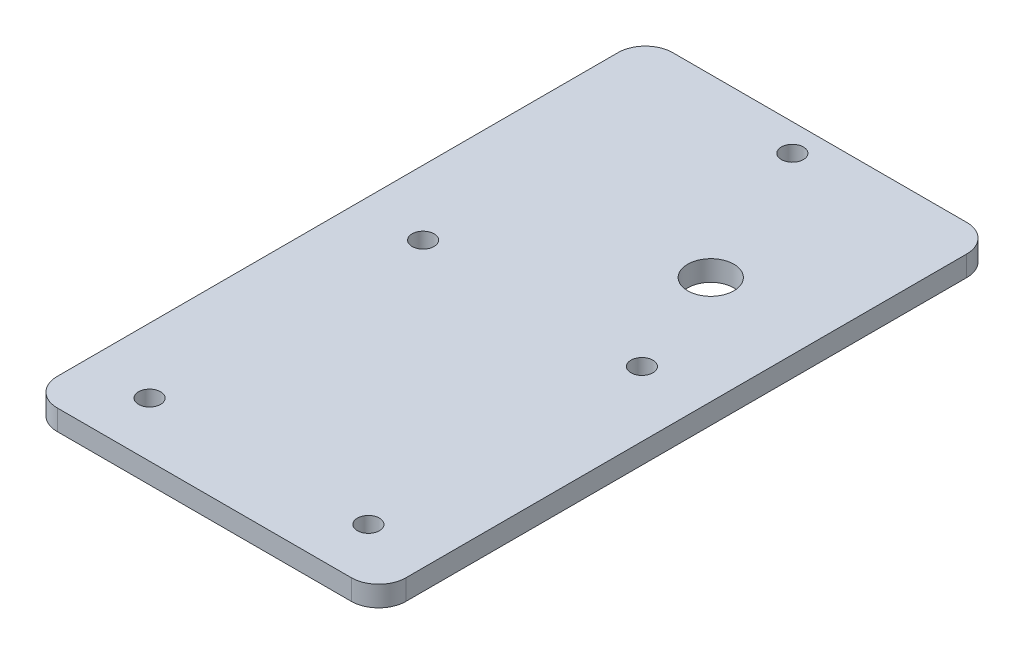
from build123d import *

# Parameters (mm, degrees)
SKETCH2_R                   = 2.5527
BOSS_EXTRUDE1_DEPTH         = 4.7625
F_1_2_13_TAPPED_HOLE1_D     = 10.71626
F_1_2_13_TAPPED_HOLE1_DEPTH = 4.7625
SKETCH5_R                   = 0.79375
CUT_EXTRUDE1_DEPTH          = 0.762
SKETCH6_W                   = 1.221153846
SKETCH6_H                   = 0.325641026
SKETCH6_W_2                 = 0.284935898
SKETCH6_H_2                 = 3.175
SKETCH6_H_3                 = 0.325641025
CUT_EXTRUDE2_DEPTH          = 0.7874


with BuildPart() as part:
    # Sketch2 → Boss-Extrude1 (new body)
    with BuildSketch(Plane(origin=(0, 0, 0), x_dir=(1, 0, 0), z_dir=(0, 1, 0))):
        with BuildLine():
            Line((-40.48125, 114.236868064), (-40.48125, -15.938131936))
            ThreePointArc((-40.48125, -15.938131936), (-38.621378061, -20.428259996), (-34.13125, -22.288131936))
            Line((-34.13125, -22.288131936), (34.13125, -22.288131936))
            ThreePointArc((34.13125, -22.288131936), (38.621378061, -20.428259996), (40.48125, -15.938131936))
            Line((40.48125, -15.938131936), (40.48125, 114.236868064))
            ThreePointArc((40.48125, 114.236868064), (38.621378061, 118.726996125), (34.13125, 120.586868064))
            Line((34.13125, 120.586868064), (-34.13125, 120.586868064))
            ThreePointArc((-34.13125, 120.586868064), (-38.621378061, 118.726996125), (-40.48125, 114.236868064))
        make_face()
        with Locations((-25.4, -9.588131936)):
            Circle(SKETCH2_R, mode=Mode.SUBTRACT)
        with Locations((25.4, -9.588131936)):
            Circle(SKETCH2_R, mode=Mode.SUBTRACT)
        with Locations((25.4, 53.911868064)):
            Circle(SKETCH2_R, mode=Mode.SUBTRACT)
        with Locations((-25.4, 53.911868064)):
            Circle(SKETCH2_R, mode=Mode.SUBTRACT)
        with Locations((0, 114.236868064)):
            Circle(SKETCH2_R, mode=Mode.SUBTRACT)
    extrude(amount=-BOSS_EXTRUDE1_DEPTH)

    # 1/2-13 Tapped Hole1
    with Locations(Plane(origin=(0, -4.7625, 0), x_dir=(-1, 0, 0), z_dir=(0, -1, 0))):
        with Locations((-15.49976282, 79.795252419)):
            Hole(F_1_2_13_TAPPED_HOLE1_D / 2, depth=F_1_2_13_TAPPED_HOLE1_DEPTH)

    # Sketch5 → Cut-Extrude1 (cut)
    with BuildSketch(Plane(origin=(0, -4.7625, 0), x_dir=(-1, 0, 0), z_dir=(0, -1, 0))):
        with Locations((0, -3.066681936)):
            Circle(SKETCH5_R)
        with Locations((-26.19375, 102.728581934)):
            Circle(SKETCH5_R)
        with Locations((26.19375, 102.728581934)):
            Circle(SKETCH5_R)
    extrude(amount=-CUT_EXTRUDE1_DEPTH, mode=Mode.SUBTRACT)

    # Sketch6 → Cut-Extrude2 (cut)
    with BuildSketch(Plane.XZ.offset(4.7625)):
        Polygon((10.463942238, -11.27657071), (10.406064634, -11.27657071), (10.406064634, -9.078493787), (10.03971848, -9.078493787), (10.03971848, -8.752852761), (10.406064634, -8.752852761), (10.406064634, -8.020160454), (10.691000531, -8.020160454), (10.691000531, -8.752852761), (12.197090275, -8.752852761), align=None)
        Polygon((10.691000531, -9.078493787), (10.691000531, -10.457380005), (11.637394762, -9.078493787), align=None, mode=Mode.SUBTRACT)
        with Locations((7.923051813, -9.2413143)):
            Rectangle(SKETCH6_W, SKETCH6_H)
        Polygon((5.806385147, -11.195160454), (5.501096685, -11.195160454), (4.442763352, -8.693067104), (3.384430018, -11.195160454), (3.079141557, -11.195160454), (4.422410788, -8.020160454), (4.463115916, -8.020160454), align=None)
        Polygon((2.468564634, -11.195160454), (0.677538993, -11.195160454), (0.677538993, -10.869519428), (2.183628736, -10.869519428), (2.183628736, -9.892596351), (0.677538993, -9.892596351), (0.677538993, -9.566955325), (2.183628736, -9.566955325), (2.183628736, -8.345801479), (0.677538993, -8.345801479), (0.677538993, -8.020160454), (2.468564634, -8.020160454), align=None)
        Polygon((0.107667198, -8.020160454), (0.107667198, -11.195160454), (0.047881541, -11.195160454), (-2.049704597, -8.696247192), (-2.049704597, -11.195160454), (-2.334640494, -11.195160454), (-2.334640494, -8.020160454), (-2.269766696, -8.020160454), (-0.1772687, -10.513349556), (-0.1772687, -8.020160454), align=None)
        Polygon((-2.782396905, -10.869519428), (-2.782396905, -11.195160454), (-4.451307161, -11.195160454), (-4.451307161, -10.869519428), (-3.759319982, -10.869519428), (-3.759319982, -8.020160454), (-3.474384084, -8.020160454), (-3.474384084, -10.869519428), align=None)
        with Locations((-6.384800751, -9.607660454)):
            Rectangle(SKETCH6_W_2, SKETCH6_H_2)
        Polygon((-7.219255879, -8.020160454), (-7.219255879, -11.195160454), (-7.279041536, -11.195160454), (-9.376627674, -8.696247192), (-9.376627674, -11.195160454), (-9.661563571, -11.195160454), (-9.661563571, -8.020160454), (-9.596689773, -8.020160454), (-7.504191776, -10.513349556), (-7.504191776, -8.020160454), align=None)
        with BuildLine():
            Line((-10.475666135, -11.195160454), (-11.098327393, -11.195160454))
            add(Edge.make_bspline(
                [(-11.098327393, -11.195160454), (-11.14115443, -11.195113376), (-11.223212933, -11.195023174), (-11.340883019, -11.192288369), (-11.447753276, -11.188635584), (-11.543593264, -11.183572009), (-11.628697868, -11.17758796), (-11.702681989, -11.169195038), (-11.766127158, -11.16043177), (-11.804142295, -11.151522351), (-11.821479437, -11.147459131)],
                knots=[0, 0, 0, 0, 0.000128477, 0.000246168, 0.000353087, 0.00044926, 0.000534089, 0.000608961, 0.000672646, 0.000726041, 0.000726041, 0.000726041, 0.000726041], degree=3))
            add(Edge.make_bspline(
                [(-11.821479437, -11.147459131), (-11.843426289, -11.141451896), (-11.886802842, -11.129578977), (-11.949307949, -11.105802008), (-12.008767162, -11.077596308), (-12.065429194, -11.045497724), (-12.11832336, -11.00799041), (-12.169101118, -10.967239159), (-12.216697585, -10.921595895), (-12.260394069, -10.87112071), (-12.300880749, -10.817467154), (-12.334771001, -10.759267087), (-12.364697428, -10.698539495), (-12.388019365, -10.633801694), (-12.406351303, -10.565908215), (-12.419702474, -10.494682353), (-12.428283556, -10.420277758), (-12.429097793, -10.369421701), (-12.429512289, -10.343532849)],
                knots=[0, 0, 0, 0, 6.8232e-05, 0.000134856, 0.000200292, 0.000265532, 0.000329934, 0.000394598, 0.000460723, 0.000527435, 0.000594727, 0.000662027, 0.00072916, 0.000797572, 0.000868081, 0.000939932, 0.001014804, 0.001092439, 0.001092439, 0.001092439, 0.001092439], degree=3))
            add(Edge.make_bspline(
                [(-12.429512289, -10.343532849), (-12.429129997, -10.317427295), (-12.428382016, -10.266350014), (-12.419404671, -10.191626127), (-12.407312283, -10.120217302), (-12.388718529, -10.052281872), (-12.364365668, -9.98822328), (-12.335797877, -9.927062591), (-12.301341389, -9.869840317), (-12.261749293, -9.816348718), (-12.217706061, -9.766537583), (-12.169398039, -9.720767877), (-12.117020252, -9.679307513), (-12.060739161, -9.642063544), (-12.000006084, -9.609899633), (-11.93574213, -9.581091221), (-11.867388719, -9.556896759), (-11.82008801, -9.544169489), (-11.796038732, -9.537698515)],
                knots=[0, 0, 0, 0, 7.8272e-05, 0.000153144, 0.000225504, 0.0002954, 0.000364034, 0.000430891, 0.000497646, 0.000564048, 0.000630282, 0.000696867, 0.000763418, 0.000830451, 0.000899029, 0.000969354, 0.001041572, 0.001116269, 0.001116269, 0.001116269, 0.001116269], degree=3))
            add(Edge.make_bspline(
                [(-11.796038732, -9.537698515), (-11.776147281, -9.533471677), (-11.73255401, -9.524208317), (-11.660764756, -9.513796559), (-11.57713832, -9.505257781), (-11.481959236, -9.497289324), (-11.375005548, -9.493067038), (-11.256522557, -9.488109386), (-11.126109277, -9.485770141), (-11.035150079, -9.485622272), (-10.987660326, -9.485545069)],
                knots=[0, 0, 0, 0, 6.0995e-05, 0.000133673, 0.000217466, 0.000313174, 0.000420146, 0.000538529, 0.000668937, 0.000811407, 0.000811407, 0.000811407, 0.000811407], degree=3))
            Line((-10.987660326, -9.485545069), (-10.760602033, -9.485545069))
            Line((-10.760602033, -9.485545069), (-10.760602033, -8.020160454))
            Line((-10.760602033, -8.020160454), (-10.475666135, -8.020160454))
            Line((-10.475666135, -8.020160454), (-10.475666135, -11.195160454))
        make_face()
        with BuildLine():
            Line((-10.760602033, -10.869519428), (-10.760602033, -9.811186095))
            Line((-10.760602033, -9.811186095), (-11.31648144, -9.804189901))
            add(Edge.make_bspline(
                [(-11.31648144, -9.804189901), (-11.343623544, -9.804172004), (-11.396020816, -9.804137455), (-11.471914654, -9.807814614), (-11.542157112, -9.811814948), (-11.6068519, -9.818284437), (-11.665703733, -9.826175199), (-11.718855099, -9.836725186), (-11.766730172, -9.847485491), (-11.821876954, -9.866156531), (-11.883647133, -9.894324164), (-11.950689653, -9.936396036), (-12.007971989, -9.989396015), (-12.057122984, -10.049631041), (-12.095973489, -10.116710556), (-12.124130134, -10.188282461), (-12.141316365, -10.264074986), (-12.143476529, -10.31588259), (-12.144576392, -10.342260814)],
                knots=[0, 0, 0, 0, 8.1413e-05, 0.000157166, 0.000227904, 0.000292456, 0.00035218, 0.000405942, 0.000454998, 0.000499245, 0.00058036, 0.000658165, 0.000735602, 0.000813379, 0.000890612, 0.000967146, 0.001043375, 0.001122449, 0.001122449, 0.001122449, 0.001122449], degree=3))
            add(Edge.make_bspline(
                [(-12.144576392, -10.342260814), (-12.143427459, -10.367784457), (-12.141143524, -10.4185223), (-12.124272098, -10.492918381), (-12.095675301, -10.563676625), (-12.057091311, -10.630224472), (-12.009118146, -10.690299403), (-11.952975038, -10.742118206), (-11.889535486, -10.784059461), (-11.830983415, -10.811979354), (-11.778583924, -10.828352201), (-11.733289329, -10.840172568), (-11.681886893, -10.848324823), (-11.624863074, -10.856124998), (-11.562290882, -10.862421437), (-11.493772435, -10.866793885), (-11.419535964, -10.869326008), (-11.368000902, -10.869453394), (-11.341286127, -10.869519428)],
                knots=[0, 0, 0, 0, 7.6536e-05, 0.000152145, 0.000227496, 0.00030473, 0.000382107, 0.000457279, 0.000532954, 0.000609493, 0.000650927, 0.000697513, 0.000749794, 0.000806912, 0.000870198, 0.000938398, 0.001012855, 0.001092996, 0.001092996, 0.001092996, 0.001092996], degree=3))
            Line((-11.341286127, -10.869519428), (-10.760602033, -10.869519428))
        make_face(mode=Mode.SUBTRACT)
        with BuildLine():
            Line((-13.080794341, -11.195160454), (-13.365730238, -11.195160454))
            Line((-13.365730238, -11.195160454), (-13.365730238, -9.292831728))
            add(Edge.make_bspline(
                [(-13.365730238, -9.292831728), (-13.365687835, -9.26590706), (-13.365607367, -9.214812864), (-13.366144861, -9.142088763), (-13.367650146, -9.077434461), (-13.368599162, -9.020600738), (-13.370710386, -8.971848389), (-13.372432185, -8.930913285), (-13.374646119, -8.897989259), (-13.377306876, -8.878775133), (-13.378450591, -8.870516023)],
                knots=[0, 0, 0, 0, 8.0774e-05, 0.000153283, 0.000218169, 0.000274789, 0.0003238, 0.00036455, 0.00039772, 0.000422728, 0.000422728, 0.000422728, 0.000422728], degree=3))
            add(Edge.make_bspline(
                [(-13.378450591, -8.870516023), (-13.383089171, -8.840488218), (-13.392043743, -8.782520892), (-13.415920368, -8.700076695), (-13.447491551, -8.625379836), (-13.487726264, -8.55759573), (-13.53735061, -8.496247781), (-13.598577204, -8.440746172), (-13.671279677, -8.390931006), (-13.75380491, -8.347234252), (-13.841789998, -8.310993067), (-13.932015226, -8.283862018), (-14.022757057, -8.267260812), (-14.083515506, -8.265343381), (-14.113686969, -8.264391223)],
                knots=[0, 0, 0, 0, 9.1077e-05, 0.00017582, 0.000256745, 0.000333753, 0.000411529, 0.000492561, 0.000580775, 0.000675242, 0.000772212, 0.000865784, 0.000957488, 0.001047945, 0.001047945, 0.001047945, 0.001047945], degree=3))
            add(Edge.make_bspline(
                [(-14.113686969, -8.264391223), (-14.139591615, -8.265359905), (-14.191251288, -8.267291674), (-14.267966792, -8.27940291), (-14.342922766, -8.300795507), (-14.415514195, -8.329951917), (-14.484621558, -8.365749352), (-14.54838686, -8.40893079), (-14.606138591, -8.458496536), (-14.658219839, -8.514214383), (-14.703551796, -8.576425768), (-14.742575743, -8.644806567), (-14.774460374, -8.719902176), (-14.790478073, -8.772825319), (-14.798677954, -8.799918066)],
                knots=[0, 0, 0, 0, 7.7722e-05, 0.000154995, 0.000232312, 0.000311088, 0.000389321, 0.000465351, 0.00054158, 0.000617184, 0.000693638, 0.000771974, 0.000852899, 0.000937778, 0.000937778, 0.000937778, 0.000937778], degree=3))
            add(Edge.make_bspline(
                [(-14.798677954, -8.799918066), (-14.801399497, -8.811119987), (-14.807464189, -8.836082381), (-14.813131152, -8.878283838), (-14.8190335, -8.928076332), (-14.82312886, -8.985817619), (-14.827121395, -9.051314216), (-14.829509969, -9.124907321), (-14.830613991, -9.206329707), (-14.830942994, -9.263150561), (-14.831114853, -9.292831728)],
                knots=[0, 0, 0, 0, 3.4562e-05, 7.7018e-05, 0.000127589, 0.000185003, 0.000250624, 0.000324446, 0.000405866, 0.000494911, 0.000494911, 0.000494911, 0.000494911], degree=3))
            Line((-14.831114853, -9.292831728), (-14.831114853, -11.195160454))
            Line((-14.831114853, -11.195160454), (-15.116050751, -11.195160454))
            Line((-15.116050751, -11.195160454), (-15.116050751, -9.277567305))
            add(Edge.make_bspline(
                [(-15.116050751, -9.277567305), (-15.115822744, -9.243006266), (-15.115377774, -9.175558299), (-15.111441581, -9.076728934), (-15.105344791, -8.982955061), (-15.096135163, -8.894354644), (-15.085944786, -8.810827971), (-15.071487885, -8.732680977), (-15.056113374, -8.659250702), (-15.036818573, -8.590401703), (-15.013866331, -8.525095139), (-14.986533502, -8.462097498), (-14.953243671, -8.401975585), (-14.915561716, -8.343627255), (-14.872716131, -8.287590229), (-14.825072252, -8.233429669), (-14.771867518, -8.181857589), (-14.714442844, -8.132627433), (-14.653264457, -8.086519375), (-14.587645992, -8.047262144), (-14.518762035, -8.014038155), (-14.447343141, -7.985740439), (-14.372182226, -7.965047675), (-14.294215494, -7.949511879), (-14.212894994, -7.940723242), (-14.157592022, -7.939413454), (-14.129587409, -7.938750197)],
                knots=[0, 0, 0, 0, 0.000103679, 0.000202335, 0.00029668, 0.000385534, 0.000469551, 0.000549023, 0.000623873, 0.000694551, 0.000763347, 0.000831413, 0.000900294, 0.000969272, 0.001039617, 0.001111715, 0.001185476, 0.001261706, 0.001338538, 0.001415, 0.001490665, 0.001567791, 0.001645108, 0.00172419, 0.001806085, 0.0018901, 0.0018901, 0.0018901, 0.0018901], degree=3))
            add(Edge.make_bspline(
                [(-14.129587409, -7.938750197), (-14.0990445, -7.939461598), (-14.039119422, -7.940857364), (-13.950823049, -7.948867846), (-13.866162229, -7.963917641), (-13.784310693, -7.983204688), (-13.706059219, -8.009370773), (-13.631430866, -8.041521913), (-13.559568747, -8.078227324), (-13.492091897, -8.121600555), (-13.428446782, -8.168896143), (-13.370607925, -8.220845161), (-13.317107081, -8.275469124), (-13.270302448, -8.334824899), (-13.228423719, -8.397697419), (-13.192393714, -8.464382402), (-13.161445199, -8.534790454), (-13.145473925, -8.583734101), (-13.137399909, -8.60847676)],
                knots=[0, 0, 0, 0, 9.1642e-05, 0.000179801, 0.000265647, 0.00034941, 0.000431872, 0.000512797, 0.000593016, 0.000673649, 0.000753152, 0.000830636, 0.000906653, 0.000982243, 0.001057036, 0.001133024, 0.001209357, 0.001287398, 0.001287398, 0.001287398, 0.001287398], degree=3))
            add(Edge.make_bspline(
                [(-13.137399909, -8.60847676), (-13.132703487, -8.625379167), (-13.122516843, -8.662040863), (-13.111608181, -8.722716464), (-13.102437799, -8.792579996), (-13.0938149, -8.871636243), (-13.088726774, -8.959946479), (-13.084265955, -9.057472424), (-13.080762915, -9.164332004), (-13.080783572, -9.238767171), (-13.080794341, -9.277567305)],
                knots=[0, 0, 0, 0, 5.2605e-05, 0.000114102, 0.000184711, 0.00026401, 0.000352601, 0.000450014, 0.000556912, 0.000673305, 0.000673305, 0.000673305, 0.000673305], degree=3))
            Line((-13.080794341, -9.277567305), (-13.080794341, -11.195160454))
        make_face()
        Polygon((-15.604512289, -10.869519428), (-15.604512289, -11.195160454), (-17.273422546, -11.195160454), (-17.273422546, -10.869519428), (-16.581435366, -10.869519428), (-16.581435366, -8.020160454), (-16.296499469, -8.020160454), (-16.296499469, -10.869519428), align=None)
        with BuildLine():
            Line((-19.499564589, -94.640344347), (-19.499564589, -94.314703322))
            Line((-19.499564589, -94.314703322), (-18.419606657, -94.314703322))
            Line((-18.419606657, -94.314703322), (-18.248517915, -93.479612176))
            add(Edge.make_bspline(
                [(-18.248517915, -93.479612176), (-18.282132886, -93.488892494), (-18.347256578, -93.506871642), (-18.443377309, -93.52683402), (-18.534628807, -93.538867672), (-18.593842893, -93.54051079), (-18.62249628, -93.541305886)],
                knots=[0, 0, 0, 0, 0.000104595, 0.000202637, 0.000294305, 0.000380252, 0.000380252, 0.000380252, 0.000380252], degree=3))
            add(Edge.make_bspline(
                [(-18.62249628, -93.541305886), (-18.657957201, -93.540563643), (-18.727682231, -93.539104208), (-18.829541876, -93.524265153), (-18.927259644, -93.502757476), (-19.019429996, -93.469674564), (-19.107538906, -93.429014055), (-19.190391836, -93.378465958), (-19.268377976, -93.318750559), (-19.341326859, -93.251092844), (-19.40709284, -93.175763391), (-19.464470126, -93.09470217), (-19.513513948, -93.008813705), (-19.552636392, -92.917307968), (-19.58435614, -92.821047302), (-19.605329273, -92.719223976), (-19.61932246, -92.612685166), (-19.620883794, -92.539836974), (-19.621679974, -92.502689099)],
                knots=[0, 0, 0, 0, 0.000106308, 0.000209029, 0.000308233, 0.000405994, 0.000502167, 0.000598919, 0.000696487, 0.000796393, 0.00089691, 0.00099591, 0.00109389, 0.001193021, 0.001293989, 0.001397402, 0.001504454, 0.001615846, 0.001615846, 0.001615846, 0.001615846], degree=3))
            add(Edge.make_bspline(
                [(-19.621679974, -92.502689099), (-19.621076193, -92.476815498), (-19.619876792, -92.425417956), (-19.61378885, -92.349085273), (-19.602029098, -92.274377383), (-19.58640982, -92.201442264), (-19.565640585, -92.130171072), (-19.541079933, -92.060395647), (-19.51168249, -91.992231427), (-19.478135984, -91.926017588), (-19.439968858, -91.863057388), (-19.399235958, -91.802617205), (-19.354851233, -91.746450472), (-19.307591669, -91.69361835), (-19.256549839, -91.645640386), (-19.202978312, -91.600515157), (-19.145679121, -91.560156724), (-19.085662407, -91.523038546), (-19.022970269, -91.489803718), (-18.956965873, -91.462080103), (-18.889098495, -91.437780068), (-18.818763158, -91.418019163), (-18.746096145, -91.402687554), (-18.670847216, -91.392246936), (-18.593393958, -91.384650478), (-18.540893162, -91.384174515), (-18.514373283, -91.383934091)],
                knots=[0, 0, 0, 0, 7.7636e-05, 0.000154223, 0.000229512, 0.000304362, 0.000377836, 0.000452065, 0.000526141, 0.000600381, 0.000674552, 0.00074688, 0.000818896, 0.000889146, 0.000959328, 0.001028872, 0.001099111, 0.001169361, 0.001240485, 0.001311721, 0.00138394, 0.001456627, 0.001530722, 0.001606547, 0.001684456, 0.001763981, 0.001763981, 0.001763981, 0.001763981], degree=3))
            add(Edge.make_bspline(
                [(-18.514373283, -91.383934091), (-18.482738265, -91.38456252), (-18.420500105, -91.385798881), (-18.32930153, -91.398672265), (-18.24161161, -91.417235859), (-18.157794037, -91.444724067), (-18.078242979, -91.480770426), (-18.001804471, -91.523323452), (-17.929877717, -91.574683268), (-17.861952432, -91.633008648), (-17.799642447, -91.697698808), (-17.742279086, -91.76647418), (-17.692609602, -91.84086018), (-17.64945172, -91.919615812), (-17.612738313, -92.002946392), (-17.583870931, -92.091045336), (-17.560578815, -92.183484702), (-17.550723889, -92.24712375), (-17.545718435, -92.279446911)],
                knots=[0, 0, 0, 0, 9.4843e-05, 0.000186593, 0.000275792, 0.000363484, 0.0004506, 0.000537458, 0.000625516, 0.000715267, 0.000805673, 0.000894681, 0.000983587, 0.001073534, 0.001163815, 0.001256333, 0.001351355, 0.001449434, 0.001449434, 0.001449434, 0.001449434], degree=3))
            Line((-17.545718435, -92.279446911), (-17.830654333, -92.279446911))
            add(Edge.make_bspline(
                [(-17.830654333, -92.279446911), (-17.837656436, -92.249163625), (-17.851114867, -92.190957466), (-17.880810079, -92.109276326), (-17.916543228, -92.036185858), (-17.961003829, -91.972145706), (-18.01150631, -91.915000274), (-18.069794348, -91.864182382), (-18.135372615, -91.81888867), (-18.20825576, -91.780825634), (-18.28534358, -91.748810021), (-18.36555339, -91.72595122), (-18.447746241, -91.712116982), (-18.503084242, -91.710425594), (-18.530909742, -91.709575117)],
                knots=[0, 0, 0, 0, 9.3172e-05, 0.000179081, 0.000260145, 0.000336534, 0.000412222, 0.000488388, 0.000567954, 0.000650749, 0.000734606, 0.000817952, 0.00090045, 0.000983887, 0.000983887, 0.000983887, 0.000983887], degree=3))
            add(Edge.make_bspline(
                [(-18.530909742, -91.709575117), (-18.558084025, -91.710325909), (-18.611590411, -91.711804226), (-18.690373808, -91.72299883), (-18.766213903, -91.740692677), (-18.839245322, -91.765480744), (-18.909109203, -91.798273902), (-18.975706766, -91.838558407), (-19.039986751, -91.885329197), (-19.100257407, -91.938786503), (-19.155444569, -91.997729943), (-19.204209811, -92.060754127), (-19.244828669, -92.12798915), (-19.279058949, -92.198268247), (-19.30505157, -92.272362399), (-19.323594464, -92.349924171), (-19.334482952, -92.431145191), (-19.335980809, -92.486543779), (-19.336744076, -92.514773434)],
                knots=[0, 0, 0, 0, 8.15e-05, 0.000160473, 0.000238226, 0.000314858, 0.000391397, 0.000469277, 0.000548023, 0.000629575, 0.000710572, 0.000789952, 0.000868161, 0.00094582, 0.001024071, 0.001103209, 0.001184703, 0.00126938, 0.00126938, 0.00126938, 0.00126938], degree=3))
            add(Edge.make_bspline(
                [(-19.336744076, -92.514773434), (-19.336261636, -92.540260609), (-19.335320765, -92.589966585), (-19.324193747, -92.662620562), (-19.30920653, -92.731972789), (-19.28556899, -92.797375279), (-19.256857857, -92.859510835), (-19.219448439, -92.916844159), (-19.178089899, -92.972178621), (-19.128560224, -93.021855965), (-19.074930997, -93.068088987), (-19.015500133, -93.10730109), (-18.951966042, -93.140663289), (-18.884180659, -93.16799363), (-18.81206874, -93.189765447), (-18.735589154, -93.204811965), (-18.654725115, -93.213815646), (-18.59941149, -93.215037035), (-18.570978852, -93.21566486)],
                knots=[0, 0, 0, 0, 7.6388e-05, 0.000148975, 0.000220101, 0.000288897, 0.000357176, 0.000424932, 0.000493881, 0.000564045, 0.000634895, 0.000705984, 0.000777107, 0.000849861, 0.000924913, 0.001002747, 0.001083378, 0.001168664, 0.001168664, 0.001168664, 0.001168664], degree=3))
            add(Edge.make_bspline(
                [(-18.570978852, -93.21566486), (-18.546155321, -93.215156066), (-18.495337698, -93.214114485), (-18.41720569, -93.205917457), (-18.335457967, -93.193307119), (-18.249777158, -93.175131597), (-18.1603984, -93.152374593), (-18.067173055, -93.123953948), (-17.970098869, -93.091216949), (-17.904760992, -93.065825017), (-17.871359461, -93.052844347)],
                knots=[0, 0, 0, 0, 7.4458e-05, 0.000152426, 0.000235453, 0.00032252, 0.000415075, 0.000512059, 0.000614836, 0.000722329, 0.000722329, 0.000722329, 0.000722329], degree=3))
            Line((-17.871359461, -93.052844347), (-18.197000487, -94.640344347))
            Line((-18.197000487, -94.640344347), (-19.499564589, -94.640344347))
        make_face()
        with Locations((-20.557897923, -92.686498194)):
            Rectangle(SKETCH6_W, SKETCH6_H_3)
        with BuildLine():
            Line((-21.697641512, -94.640344347), (-22.32030277, -94.640344347))
            add(Edge.make_bspline(
                [(-22.32030277, -94.640344347), (-22.363129807, -94.64029727), (-22.44518831, -94.640207068), (-22.562858396, -94.637472263), (-22.669728653, -94.633819478), (-22.765568641, -94.628755903), (-22.850673245, -94.622771853), (-22.924657366, -94.614378932), (-22.988102535, -94.605615664), (-23.026117672, -94.596706245), (-23.043454814, -94.592643025)],
                knots=[0, 0, 0, 0, 0.000128477, 0.000246168, 0.000353087, 0.00044926, 0.000534089, 0.000608961, 0.000672646, 0.000726041, 0.000726041, 0.000726041, 0.000726041], degree=3))
            add(Edge.make_bspline(
                [(-23.043454814, -94.592643025), (-23.065401666, -94.586635789), (-23.108778219, -94.574762871), (-23.171283326, -94.550985902), (-23.230742539, -94.522780202), (-23.287404571, -94.490681618), (-23.340298737, -94.453174303), (-23.391076495, -94.412423053), (-23.438672962, -94.366779788), (-23.482369446, -94.316304604), (-23.522856126, -94.262651047), (-23.556746378, -94.204450981), (-23.586672805, -94.143723388), (-23.609994742, -94.078985588), (-23.62832668, -94.011092109), (-23.641677851, -93.939866247), (-23.650258933, -93.865461652), (-23.65107317, -93.814605595), (-23.651487666, -93.788716743)],
                knots=[0, 0, 0, 0, 6.8232e-05, 0.000134856, 0.000200292, 0.000265532, 0.000329934, 0.000394598, 0.000460723, 0.000527435, 0.000594727, 0.000662027, 0.00072916, 0.000797572, 0.000868081, 0.000939932, 0.001014804, 0.001092439, 0.001092439, 0.001092439, 0.001092439], degree=3))
            add(Edge.make_bspline(
                [(-23.651487666, -93.788716743), (-23.651105374, -93.762611189), (-23.650357393, -93.711533908), (-23.641380048, -93.636810021), (-23.62928766, -93.565401196), (-23.610693906, -93.497465766), (-23.586341045, -93.433407174), (-23.557773254, -93.372246485), (-23.523316766, -93.315024211), (-23.48372467, -93.261532612), (-23.439681438, -93.211721477), (-23.391373416, -93.165951771), (-23.338995629, -93.124491406), (-23.282714538, -93.087247437), (-23.22198146, -93.055083527), (-23.157717507, -93.026275114), (-23.089364096, -93.002080652), (-23.042063387, -92.989353382), (-23.018014109, -92.982882408)],
                knots=[0, 0, 0, 0, 7.8272e-05, 0.000153144, 0.000225504, 0.0002954, 0.000364034, 0.000430891, 0.000497646, 0.000564048, 0.000630282, 0.000696867, 0.000763418, 0.000830451, 0.000899029, 0.000969354, 0.001041572, 0.001116269, 0.001116269, 0.001116269, 0.001116269], degree=3))
            add(Edge.make_bspline(
                [(-23.018014109, -92.982882408), (-22.998122658, -92.978655571), (-22.954529386, -92.969392211), (-22.882740133, -92.958980453), (-22.799113697, -92.950441675), (-22.703934613, -92.942473218), (-22.596980925, -92.938250932), (-22.478497934, -92.93329328), (-22.348084653, -92.930954035), (-22.257125456, -92.930806165), (-22.209635703, -92.930728963)],
                knots=[0, 0, 0, 0, 6.0995e-05, 0.000133673, 0.000217466, 0.000313174, 0.000420146, 0.000538529, 0.000668937, 0.000811407, 0.000811407, 0.000811407, 0.000811407], degree=3))
            Line((-22.209635703, -92.930728963), (-21.98257741, -92.930728963))
            Line((-21.98257741, -92.930728963), (-21.98257741, -91.465344347))
            Line((-21.98257741, -91.465344347), (-21.697641512, -91.465344347))
            Line((-21.697641512, -91.465344347), (-21.697641512, -94.640344347))
        make_face()
        with BuildLine():
            Line((-21.98257741, -94.314703322), (-21.98257741, -93.256369988))
            Line((-21.98257741, -93.256369988), (-22.538456817, -93.249373794))
            add(Edge.make_bspline(
                [(-22.538456817, -93.249373794), (-22.565598921, -93.249355898), (-22.617996193, -93.249321349), (-22.693890031, -93.252998507), (-22.764132489, -93.256998841), (-22.828827277, -93.263468331), (-22.887679109, -93.271359093), (-22.940830475, -93.28190908), (-22.988705549, -93.292669385), (-23.043852331, -93.311340425), (-23.10562251, -93.339508058), (-23.17266503, -93.381579929), (-23.229947365, -93.434579908), (-23.279098361, -93.494814935), (-23.317948866, -93.56189445), (-23.346105511, -93.633466355), (-23.363291742, -93.709258879), (-23.365451906, -93.761066484), (-23.366551769, -93.787444708)],
                knots=[0, 0, 0, 0, 8.1413e-05, 0.000157166, 0.000227904, 0.000292456, 0.00035218, 0.000405942, 0.000454998, 0.000499245, 0.00058036, 0.000658165, 0.000735602, 0.000813379, 0.000890612, 0.000967146, 0.001043375, 0.001122449, 0.001122449, 0.001122449, 0.001122449], degree=3))
            add(Edge.make_bspline(
                [(-23.366551769, -93.787444708), (-23.365402836, -93.812968351), (-23.363118901, -93.863706194), (-23.346247475, -93.938102275), (-23.317650678, -94.008860519), (-23.279066688, -94.075408366), (-23.231093523, -94.135483296), (-23.174950415, -94.1873021), (-23.111510862, -94.229243355), (-23.052958792, -94.257163248), (-23.000559301, -94.273536095), (-22.955264706, -94.285356461), (-22.90386227, -94.293508717), (-22.846838451, -94.301308892), (-22.784266259, -94.307605331), (-22.715747812, -94.311977779), (-22.641511341, -94.314509902), (-22.589976279, -94.314637288), (-22.563261504, -94.314703322)],
                knots=[0, 0, 0, 0, 7.6536e-05, 0.000152145, 0.000227496, 0.00030473, 0.000382107, 0.000457279, 0.000532954, 0.000609493, 0.000650927, 0.000697513, 0.000749794, 0.000806912, 0.000870198, 0.000938398, 0.001012855, 0.001092996, 0.001092996, 0.001092996, 0.001092996], degree=3))
            Line((-22.563261504, -94.314703322), (-21.98257741, -94.314703322))
        make_face(mode=Mode.SUBTRACT)
        Polygon((-25.60533382, -94.640344347), (-27.070718435, -91.465344347), (-26.760977851, -91.465344347), (-26.291596841, -92.482972552), (-24.852288948, -92.482972552), (-24.369551568, -91.465344347), (-24.058538948, -91.465344347), (-25.564628692, -94.640344347), align=None)
        Polygon((-25.581801168, -94.021499195), (-25.006841232, -92.808613578), (-26.141496681, -92.808613578), align=None, mode=Mode.SUBTRACT)
        Polygon((-27.19283382, -94.314703322), (-27.19283382, -94.640344347), (-28.861744076, -94.640344347), (-28.861744076, -94.314703322), (-28.169756897, -94.314703322), (-28.169756897, -91.465344347), (-27.884821, -91.465344347), (-27.884821, -94.314703322), align=None)
        with Locations((-29.57408382, -93.052844347)):
            Rectangle(SKETCH6_W_2, SKETCH6_H_2)
        Polygon((-30.408538948, -94.640344347), (-32.199564589, -94.640344347), (-32.199564589, -94.314703322), (-30.693474846, -94.314703322), (-30.693474846, -93.337780245), (-32.199564589, -93.337780245), (-32.199564589, -93.012139219), (-30.693474846, -93.012139219), (-30.693474846, -91.790985373), (-32.199564589, -91.790985373), (-32.199564589, -91.465344347), (-30.408538948, -91.465344347), align=None)
        Polygon((-32.769436384, -91.465344347), (-32.769436384, -94.640344347), (-32.829222041, -94.640344347), (-34.926808179, -92.141431086), (-34.926808179, -94.640344347), (-35.211744076, -94.640344347), (-35.211744076, -91.465344347), (-35.146870278, -91.465344347), (-33.054372282, -93.95853345), (-33.054372282, -91.465344347), align=None)
        Polygon((-35.659500487, -94.314703322), (-35.659500487, -94.640344347), (-37.328410743, -94.640344347), (-37.328410743, -94.314703322), (-36.636423564, -94.314703322), (-36.636423564, -91.465344347), (-36.351487666, -91.465344347), (-36.351487666, -94.314703322), align=None)
        with BuildLine():
            Line((34.524303325, -94.721754604), (34.304877243, -94.549393827))
            Line((34.304877243, -94.549393827), (35.143784495, -93.26654627))
            add(Edge.make_bspline(
                [(35.143784495, -93.26654627), (35.087931458, -93.275448844), (34.978983794, -93.29281432), (34.868706158, -93.295679028), (34.814963381, -93.297075117)],
                knots=[0, 0, 0, 0, 0.000169463, 0.000330556, 0.000330556, 0.000330556, 0.000330556], degree=3))
            add(Edge.make_bspline(
                [(34.814963381, -93.297075117), (34.782694045, -93.296207787), (34.719172817, -93.294500474), (34.625912362, -93.281361552), (34.536296681, -93.260655916), (34.450697231, -93.230473221), (34.368806693, -93.191917535), (34.290155413, -93.145708623), (34.21622076, -93.089460918), (34.146054836, -93.026626534), (34.082338978, -92.957037638), (34.02597203, -92.883179196), (33.978365433, -92.805057049), (33.940436993, -92.722688764), (33.910125453, -92.63671911), (33.888547325, -92.546812798), (33.875647596, -92.452818086), (33.873905968, -92.388882409), (33.873021274, -92.356405044)],
                knots=[0, 0, 0, 0, 9.6777e-05, 0.000190503, 0.000281986, 0.000372302, 0.000462213, 0.000553183, 0.000645406, 0.000740428, 0.000835408, 0.000928014, 0.001018766, 0.001109253, 0.00119957, 0.001291818, 0.001386174, 0.001483587, 0.001483587, 0.001483587, 0.001483587], degree=3))
            add(Edge.make_bspline(
                [(33.873021274, -92.356405044), (33.874675083, -92.311998223), (33.877927469, -92.22466763), (33.901692471, -92.096967753), (33.942403175, -91.976359118), (33.997744618, -91.862526803), (34.06817858, -91.757854698), (34.152658799, -91.663573755), (34.250768185, -91.581394728), (34.360553326, -91.510927652), (34.47935889, -91.454933594), (34.603934648, -91.413538108), (34.73321064, -91.388802785), (34.82100701, -91.385564454), (34.865208774, -91.383934091)],
                knots=[0, 0, 0, 0, 0.000133185, 0.000261921, 0.000388028, 0.000514038, 0.000640517, 0.000765276, 0.000892559, 0.001023291, 0.001155584, 0.001285512, 0.001416242, 0.001548791, 0.001548791, 0.001548791, 0.001548791], degree=3))
            add(Edge.make_bspline(
                [(34.865208774, -91.383934091), (34.907934016, -91.385316449), (34.99256524, -91.388054658), (35.117028568, -91.412574286), (35.23683501, -91.452033475), (35.350443929, -91.507536459), (35.455868109, -91.576455907), (35.55091018, -91.658860802), (35.633165234, -91.754804595), (35.701868822, -91.862496945), (35.758091417, -91.977306794), (35.797374973, -92.098323256), (35.822916025, -92.223038302), (35.825544402, -92.307943055), (35.826867427, -92.350680886)],
                knots=[0, 0, 0, 0, 0.000128067, 0.000253679, 0.000378981, 0.000505562, 0.000631868, 0.000755839, 0.000881669, 0.001009574, 0.00113815, 0.001264056, 0.001390412, 0.001518479, 0.001518479, 0.001518479, 0.001518479], degree=3))
            add(Edge.make_bspline(
                [(35.826867427, -92.350680886), (35.825716764, -92.383366567), (35.823368374, -92.450074784), (35.809353452, -92.551398504), (35.783648372, -92.654668158), (35.755829859, -92.742212572), (35.728225495, -92.814715208), (35.702630095, -92.871968625), (35.674011318, -92.932430071), (35.640466126, -92.994955556), (35.604905515, -93.06133157), (35.563366687, -93.129100006), (35.520020281, -93.200735975), (35.48826581, -93.248430091), (35.471969591, -93.272906447)],
                knots=[0, 0, 0, 0, 9.8079e-05, 0.000200169, 0.000306148, 0.000416977, 0.000475563, 0.000538786, 0.000605069, 0.000676192, 0.000751621, 0.00083092, 0.000914587, 0.001002789, 0.001002789, 0.001002789, 0.001002789], degree=3))
            Line((35.471969591, -93.272906447), (34.524303325, -94.721754604))
        make_face()
        with BuildLine():
            add(Edge.make_bspline(
                [(34.874749038, -92.971434091), (34.898937137, -92.970725816), (34.946393988, -92.969336185), (35.015891585, -92.961314485), (35.081705908, -92.946632536), (35.143728957, -92.925966238), (35.202876074, -92.90071736), (35.258207757, -92.868698663), (35.310096388, -92.831045372), (35.357343688, -92.787706947), (35.400739757, -92.740981854), (35.438064597, -92.690627026), (35.470296864, -92.638190623), (35.496494592, -92.583177257), (35.516896897, -92.525622879), (35.531654363, -92.465788237), (35.539867452, -92.403273165), (35.541233813, -92.360880102), (35.54193153, -92.339232568)],
                knots=[0, 0, 0, 0, 7.2576e-05, 0.000142393, 0.000209516, 0.00027448, 0.000338285, 0.000402106, 0.000465841, 0.00053023, 0.000594149, 0.00065686, 0.000717945, 0.00077854, 0.000839292, 0.000900842, 0.000963087, 0.001028039, 0.001028039, 0.001028039, 0.001028039], degree=3))
            add(Edge.make_bspline(
                [(35.54193153, -92.339232568), (35.541341747, -92.317783221), (35.540179507, -92.27551465), (35.530329741, -92.213454658), (35.514474679, -92.153923865), (35.491935539, -92.096796694), (35.463141192, -92.042160003), (35.428701637, -91.989353301), (35.38694071, -91.939782241), (35.339499418, -91.893140882), (35.287948979, -91.850460227), (35.233544109, -91.812301195), (35.176089596, -91.780628442), (35.116197313, -91.75415452), (35.053114831, -91.734704937), (34.987910416, -91.719804341), (34.919685537, -91.711660335), (34.873496529, -91.710279312), (34.849944351, -91.709575117)],
                knots=[0, 0, 0, 0, 6.4316e-05, 0.000126743, 0.000187993, 0.000248818, 0.000310551, 0.000372998, 0.000437575, 0.000504586, 0.000572339, 0.000638148, 0.00070363, 0.000768855, 0.000834229, 0.000901352, 0.000969275, 0.001039945, 0.001039945, 0.001039945, 0.001039945], degree=3))
            add(Edge.make_bspline(
                [(34.849944351, -91.709575117), (34.826392133, -91.710279257), (34.780203049, -91.711660172), (34.71197872, -91.719804958), (34.646772277, -91.734702675), (34.583697162, -91.754162714), (34.523777556, -91.78059786), (34.466272777, -91.812500844), (34.411348442, -91.8502289), (34.35983153, -91.893214688), (34.312192257, -91.939517657), (34.271390933, -91.989806428), (34.235840713, -92.04174442), (34.208144501, -92.097014012), (34.185353001, -92.153889893), (34.169575614, -92.21346393), (34.159704849, -92.275512231), (34.158545492, -92.317782406), (34.157957171, -92.339232568)],
                knots=[0, 0, 0, 0, 7.067e-05, 0.000138593, 0.000205716, 0.00027109, 0.000336315, 0.000401797, 0.000468129, 0.000535882, 0.000602894, 0.000667065, 0.000729864, 0.000791304, 0.00085213, 0.000913379, 0.000975806, 0.001040123, 0.001040123, 0.001040123, 0.001040123], degree=3))
            add(Edge.make_bspline(
                [(34.157957171, -92.339232568), (34.158450547, -92.360910856), (34.159418884, -92.403458283), (34.170583402, -92.465731914), (34.185662937, -92.526109433), (34.210032865, -92.583230695), (34.239059382, -92.638675506), (34.276037477, -92.690858552), (34.318432932, -92.741260787), (34.367534255, -92.788016661), (34.420939766, -92.830813571), (34.477777956, -92.868478424), (34.537001653, -92.900630315), (34.599447963, -92.926000449), (34.664275926, -92.946438986), (34.731933389, -92.961216144), (34.802468418, -92.969348675), (34.850348617, -92.970730098), (34.874749038, -92.971434091)],
                knots=[0, 0, 0, 0, 6.4952e-05, 0.000127479, 0.000189343, 0.000251233, 0.000313264, 0.000376779, 0.000442662, 0.000510585, 0.000579817, 0.000647731, 0.000714888, 0.000781621, 0.000849612, 0.000918599, 0.000989048, 0.001062259, 0.001062259, 0.001062259, 0.001062259], degree=3))
        make_face(mode=Mode.SUBTRACT)
        with Locations((32.936803325, -92.686498194)):
            Rectangle(SKETCH6_W, SKETCH6_H_3)
        Polygon((31.797059735, -94.640344347), (30.250264863, -94.640344347), (30.250264863, -94.314703322), (31.512123838, -94.314703322), (31.512123838, -93.337780245), (30.250264863, -93.337780245), (30.250264863, -93.012139219), (31.512123838, -93.012139219), (31.512123838, -91.465344347), (31.797059735, -91.465344347), align=None)
        with Locations((29.53792512, -93.052844347)):
            Rectangle(SKETCH6_W_2, SKETCH6_H_2)
        Polygon((28.703469992, -94.640344347), (28.418534094, -94.640344347), (28.418534094, -91.790985373), (27.197380248, -91.790985373), (27.197380248, -91.465344347), (28.703469992, -91.465344347), align=None)
        Polygon((27.034559735, -94.314703322), (27.034559735, -94.640344347), (25.365649479, -94.640344347), (25.365649479, -94.314703322), (26.057636658, -94.314703322), (26.057636658, -91.465344347), (26.342572556, -91.465344347), (26.342572556, -94.314703322), align=None)
        Polygon((24.795777684, -94.640344347), (23.004752043, -94.640344347), (23.004752043, -94.314703322), (24.510841786, -94.314703322), (24.510841786, -93.337780245), (23.004752043, -93.337780245), (23.004752043, -93.012139219), (24.510841786, -93.012139219), (24.510841786, -91.790985373), (23.004752043, -91.790985373), (23.004752043, -91.465344347), (24.795777684, -91.465344347), align=None)
        with BuildLine():
            Line((22.434880248, -94.640344347), (21.799498637, -94.640344347))
            add(Edge.make_bspline(
                [(21.799498637, -94.640344347), (21.757097757, -94.640203209), (21.675683368, -94.639932207), (21.559049045, -94.638421122), (21.453070178, -94.634090099), (21.357802181, -94.630363027), (21.273246801, -94.623566766), (21.199144759, -94.617071036), (21.135837347, -94.608567787), (21.097514325, -94.600670724), (21.0801627, -94.597095149)],
                knots=[0, 0, 0, 0, 0.000127205, 0.000244248, 0.000349896, 0.000445402, 0.000530231, 0.00060434, 0.000668562, 0.000721699, 0.000721699, 0.000721699, 0.000721699], degree=3))
            add(Edge.make_bspline(
                [(21.0801627, -94.597095149), (21.056933443, -94.591356504), (21.010970471, -94.580001636), (20.944800014, -94.555989778), (20.881719658, -94.528247419), (20.821960404, -94.495414111), (20.765537912, -94.458044285), (20.712457867, -94.415987714), (20.663431968, -94.368884058), (20.616715948, -94.318684537), (20.575923939, -94.263203524), (20.53920031, -94.205256535), (20.508372081, -94.143727944), (20.484113706, -94.078928089), (20.463777199, -94.011492624), (20.450109168, -93.940755193), (20.441596479, -93.866945942), (20.440755425, -93.816725346), (20.440328966, -93.791260814)],
                knots=[0, 0, 0, 0, 7.1738e-05, 0.000141945, 0.000210849, 0.000278309, 0.000346223, 0.000413668, 0.000481152, 0.000550033, 0.000619105, 0.000687399, 0.000755663, 0.000825118, 0.000894749, 0.00096672, 0.00104096, 0.001117325, 0.001117325, 0.001117325, 0.001117325], degree=3))
            add(Edge.make_bspline(
                [(20.440328966, -93.791260814), (20.441661523, -93.748956063), (20.444261686, -93.666408537), (20.468505655, -93.546611132), (20.508215446, -93.434858338), (20.562943795, -93.331305678), (20.632605947, -93.237917117), (20.716324014, -93.156168331), (20.813670452, -93.087127756), (20.904719069, -93.039759837), (20.985184803, -93.009281288), (21.051623646, -92.987728814), (21.124152225, -92.971357628), (21.201730007, -92.956478508), (21.28495621, -92.945124543), (21.373663237, -92.937061071), (21.468072949, -92.931876196), (21.532788304, -92.931118664), (21.566080168, -92.930728963)],
                knots=[0, 0, 0, 0, 0.000126797, 0.000247415, 0.000364897, 0.000481551, 0.000597433, 0.000713022, 0.000831097, 0.00095427, 0.001019706, 0.001089102, 0.001163613, 0.001242574, 0.001326045, 0.001415471, 0.001509739, 0.001609612, 0.001609612, 0.001609612, 0.001609612], degree=3))
            Line((21.566080168, -92.930728963), (20.399623838, -91.465344347))
            Line((20.399623838, -91.465344347), (20.751977604, -91.465344347))
            Line((20.751977604, -91.465344347), (21.918433934, -92.930728963))
            Line((21.918433934, -92.930728963), (22.149944351, -92.930728963))
            Line((22.149944351, -92.930728963), (22.149944351, -91.465344347))
            Line((22.149944351, -91.465344347), (22.434880248, -91.465344347))
            Line((22.434880248, -91.465344347), (22.434880248, -94.640344347))
        make_face()
        with BuildLine():
            Line((22.149944351, -94.314703322), (22.149944351, -93.256369988))
            Line((22.149944351, -93.256369988), (21.568624238, -93.251917865))
            add(Edge.make_bspline(
                [(21.568624238, -93.251917865), (21.541482485, -93.251905851), (21.488874038, -93.251882563), (21.412764195, -93.255505582), (21.341897936, -93.259626703), (21.276547209, -93.265931812), (21.21667988, -93.274052766), (21.162335492, -93.284226831), (21.113393953, -93.296029908), (21.056495557, -93.31448493), (20.992228724, -93.342462848), (20.923825327, -93.385845043), (20.864008514, -93.438309413), (20.814277439, -93.499060338), (20.774333383, -93.566141914), (20.746588678, -93.638035987), (20.728305079, -93.713609794), (20.726289953, -93.765500284), (20.725264863, -93.791896831)],
                knots=[0, 0, 0, 0, 8.1413e-05, 0.000157801, 0.000228539, 0.000294357, 0.000354712, 0.000409723, 0.000460165, 0.000505621, 0.000589056, 0.00066969, 0.000747651, 0.000826724, 0.000904279, 0.000980813, 0.001057183, 0.001136257, 0.001136257, 0.001136257, 0.001136257], degree=3))
            add(Edge.make_bspline(
                [(20.725264863, -93.791896831), (20.726341857, -93.817434788), (20.728476064, -93.868041699), (20.746297564, -93.941962171), (20.77539725, -94.012250837), (20.815227251, -94.07794048), (20.864799959, -94.137127776), (20.922541, -94.187614624), (20.987091597, -94.229557659), (21.046934201, -94.257231775), (21.10081362, -94.273515268), (21.147378661, -94.285335438), (21.200451906, -94.293613749), (21.259408689, -94.301227584), (21.324508003, -94.307675335), (21.39578952, -94.311955035), (21.473202272, -94.314513019), (21.526856974, -94.314638411), (21.554631851, -94.314703322)],
                knots=[0, 0, 0, 0, 7.6536e-05, 0.000151667, 0.000226669, 0.000304005, 0.000381204, 0.00045737, 0.000533227, 0.000611498, 0.000654145, 0.000701964, 0.0007555, 0.00081514, 0.000880324, 0.000951697, 0.001029333, 0.001112654, 0.001112654, 0.001112654, 0.001112654], degree=3))
            Line((21.554631851, -94.314703322), (22.149944351, -94.314703322))
        make_face(mode=Mode.SUBTRACT)
        Polygon((24.155351924, -70.476333136), (22.20150577, -70.476333136), (23.870416026, -67.219922879), (24.116554848, -67.355394634), (22.683607132, -70.15069211), (24.155351924, -70.15069211), align=None)
        with Locations((21.305992949, -68.522486982)):
            Rectangle(SKETCH6_W, SKETCH6_H)
        Polygon((20.166249359, -70.476333136), (18.375223718, -70.476333136), (18.375223718, -70.15069211), (19.881313462, -70.15069211), (19.881313462, -69.173769033), (18.375223718, -69.173769033), (18.375223718, -68.848128007), (19.881313462, -68.848128007), (19.881313462, -67.626974161), (18.375223718, -67.626974161), (18.375223718, -67.301333136), (20.166249359, -67.301333136), align=None)
        Polygon((18.029230129, -70.476333136), (17.700409015, -70.476333136), (16.869133975, -69.177585139), (16.037858935, -70.476333136), (15.709037821, -70.476333136), (16.704405409, -68.920634017), (15.668332693, -67.301333136), (15.997153807, -67.301333136), (16.869133975, -68.663682895), (17.741114143, -67.301333136), (18.069935257, -67.301333136), (17.033226523, -68.920634017), align=None)
        with BuildLine():
            Line((15.118813462, -70.476333136), (14.496152204, -70.476333136))
            add(Edge.make_bspline(
                [(14.496152204, -70.476333136), (14.453325168, -70.476286058), (14.371266664, -70.476195856), (14.253596578, -70.473461051), (14.146726321, -70.469808266), (14.050886333, -70.464744691), (13.96578173, -70.458760642), (13.891797608, -70.45036772), (13.828352439, -70.441604452), (13.790337303, -70.432695033), (13.773000161, -70.428631814)],
                knots=[0, 0, 0, 0, 0.000128477, 0.000246168, 0.000353087, 0.00044926, 0.000534089, 0.000608961, 0.000672646, 0.000726041, 0.000726041, 0.000726041, 0.000726041], degree=3))
            add(Edge.make_bspline(
                [(13.773000161, -70.428631814), (13.751053309, -70.422624578), (13.707676755, -70.410751659), (13.645171648, -70.38697469), (13.585712436, -70.35876899), (13.529050404, -70.326670406), (13.476156237, -70.289163092), (13.425378479, -70.248411841), (13.377782012, -70.202768577), (13.334085528, -70.152293392), (13.293598849, -70.098639836), (13.259708596, -70.040439769), (13.229782169, -69.979712177), (13.206460233, -69.914974376), (13.188128294, -69.847080897), (13.174777124, -69.775855035), (13.166196041, -69.70145044), (13.165381805, -69.650594383), (13.164967308, -69.624705531)],
                knots=[0, 0, 0, 0, 6.8232e-05, 0.000134856, 0.000200292, 0.000265532, 0.000329934, 0.000394598, 0.000460723, 0.000527435, 0.000594727, 0.000662027, 0.00072916, 0.000797572, 0.000868081, 0.000939932, 0.001014804, 0.001092439, 0.001092439, 0.001092439, 0.001092439], degree=3))
            add(Edge.make_bspline(
                [(13.164967308, -69.624705531), (13.165349601, -69.598599977), (13.166097582, -69.547522696), (13.175074926, -69.47279881), (13.187167314, -69.401389984), (13.205761069, -69.333454554), (13.230113929, -69.269395962), (13.25868172, -69.208235273), (13.293138208, -69.151012999), (13.332730304, -69.0975214), (13.376773536, -69.047710265), (13.425081559, -69.001940559), (13.477459345, -68.960480195), (13.533740437, -68.923236226), (13.594473514, -68.891072315), (13.658737468, -68.862263903), (13.727090878, -68.838069441), (13.774391587, -68.825342171), (13.798440866, -68.818871197)],
                knots=[0, 0, 0, 0, 7.8272e-05, 0.000153144, 0.000225504, 0.0002954, 0.000364034, 0.000430891, 0.000497646, 0.000564048, 0.000630282, 0.000696867, 0.000763418, 0.000830451, 0.000899029, 0.000969354, 0.001041572, 0.001116269, 0.001116269, 0.001116269, 0.001116269], degree=3))
            add(Edge.make_bspline(
                [(13.798440866, -68.818871197), (13.818332317, -68.814644359), (13.861925588, -68.805380999), (13.933714841, -68.794969241), (14.017341277, -68.786430463), (14.112520362, -68.778462006), (14.219474049, -68.77423972), (14.33795704, -68.769282068), (14.468370321, -68.766942823), (14.559329518, -68.766794954), (14.606819271, -68.766717751)],
                knots=[0, 0, 0, 0, 6.0995e-05, 0.000133673, 0.000217466, 0.000313174, 0.000420146, 0.000538529, 0.000668937, 0.000811407, 0.000811407, 0.000811407, 0.000811407], degree=3))
            Line((14.606819271, -68.766717751), (14.833877565, -68.766717751))
            Line((14.833877565, -68.766717751), (14.833877565, -67.301333136))
            Line((14.833877565, -67.301333136), (15.118813462, -67.301333136))
            Line((15.118813462, -67.301333136), (15.118813462, -70.476333136))
        make_face()
        with BuildLine():
            Line((14.833877565, -70.15069211), (14.833877565, -69.092358777))
            Line((14.833877565, -69.092358777), (14.277998158, -69.085362583))
            add(Edge.make_bspline(
                [(14.277998158, -69.085362583), (14.250856054, -69.085344686), (14.198458782, -69.085310137), (14.122564943, -69.088987296), (14.052322485, -69.09298763), (13.987627698, -69.099457119), (13.928775865, -69.107347881), (13.875624499, -69.117897868), (13.827749426, -69.128658173), (13.772602644, -69.147329213), (13.710832464, -69.175496846), (13.643789944, -69.217568718), (13.586507609, -69.270568697), (13.537356613, -69.330803723), (13.498506109, -69.397883238), (13.470349464, -69.469455143), (13.453163232, -69.545247668), (13.451003069, -69.597055272), (13.449903206, -69.623433496)],
                knots=[0, 0, 0, 0, 8.1413e-05, 0.000157166, 0.000227904, 0.000292456, 0.00035218, 0.000405942, 0.000454998, 0.000499245, 0.00058036, 0.000658165, 0.000735602, 0.000813379, 0.000890612, 0.000967146, 0.001043375, 0.001122449, 0.001122449, 0.001122449, 0.001122449], degree=3))
            add(Edge.make_bspline(
                [(13.449903206, -69.623433496), (13.451052138, -69.648957139), (13.453336074, -69.699694982), (13.470207499, -69.774091063), (13.498804296, -69.844849307), (13.537388286, -69.911397154), (13.585361451, -69.971472085), (13.64150456, -70.023290888), (13.704944112, -70.065232143), (13.763496182, -70.093152036), (13.815895674, -70.109524883), (13.861190269, -70.12134525), (13.912592705, -70.129497505), (13.969616523, -70.13729768), (14.032188715, -70.143594119), (14.100707162, -70.147966568), (14.174943634, -70.15049869), (14.226478696, -70.150626076), (14.25319347, -70.15069211)],
                knots=[0, 0, 0, 0, 7.6536e-05, 0.000152145, 0.000227496, 0.00030473, 0.000382107, 0.000457279, 0.000532954, 0.000609493, 0.000650927, 0.000697513, 0.000749794, 0.000806912, 0.000870198, 0.000938398, 0.001012855, 0.001092996, 0.001092996, 0.001092996, 0.001092996], degree=3))
            Line((14.25319347, -70.15069211), (14.833877565, -70.15069211))
        make_face(mode=Mode.SUBTRACT)
        with BuildLine():
            add(Edge.make_bspline(
                [(12.289807052, -67.789794674), (12.272114408, -67.788778769), (12.237633964, -67.786798914), (12.187705238, -67.772247969), (12.142079395, -67.747696335), (12.101689498, -67.713962139), (12.068120318, -67.673688099), (12.043286183, -67.628178158), (12.028068262, -67.578104681), (12.026187194, -67.543126849), (12.025223718, -67.525211341)],
                knots=[0, 0, 0, 0, 5.3034e-05, 0.000103356, 0.000154574, 0.000207425, 0.000260276, 0.000310934, 0.000362045, 0.000415713, 0.000415713, 0.000415713, 0.000415713], degree=3))
            add(Edge.make_bspline(
                [(12.025223718, -67.525211341), (12.026222321, -67.50772361), (12.028194949, -67.47317853), (12.043293315, -67.423527521), (12.068088832, -67.377965912), (12.10190206, -67.337787175), (12.141835342, -67.303241089), (12.187849878, -67.279030111), (12.237505234, -67.263412863), (12.272091206, -67.261571303), (12.289807052, -67.260628007)],
                knots=[0, 0, 0, 0, 5.2401e-05, 0.000103513, 0.000154171, 0.000207022, 0.00026028, 0.000311498, 0.000362001, 0.000415035, 0.000415035, 0.000415035, 0.000415035], degree=3))
            add(Edge.make_bspline(
                [(12.289807052, -67.260628007), (12.307510148, -67.261606835), (12.342274545, -67.263529004), (12.39211572, -67.278719623), (12.437851495, -67.303477338), (12.477795157, -67.33772483), (12.511336578, -67.378175146), (12.537283233, -67.42321732), (12.551176955, -67.473322124), (12.553309145, -67.507751895), (12.554390385, -67.525211341)],
                knots=[0, 0, 0, 0, 5.3034e-05, 0.000104146, 0.000154804, 0.000208063, 0.000260913, 0.000311878, 0.000362811, 0.000415212, 0.000415212, 0.000415212, 0.000415212], degree=3))
            add(Edge.make_bspline(
                [(12.554390385, -67.525211341), (12.553341353, -67.543097565), (12.551296733, -67.57795877), (12.537289553, -67.628488072), (12.511305034, -67.673478646), (12.478007016, -67.714023998), (12.437609908, -67.747463804), (12.39225761, -67.77255416), (12.342147829, -67.786684429), (12.307487458, -67.788744051), (12.289807052, -67.789794674)],
                knots=[0, 0, 0, 0, 5.3667e-05, 0.0001046, 0.000155565, 0.000208416, 0.000261267, 0.000311925, 0.000362858, 0.000415892, 0.000415892, 0.000415892, 0.000415892], degree=3))
        make_face()
        with BuildLine():
            Line((10.071377565, -70.476333136), (9.435995954, -70.476333136))
            add(Edge.make_bspline(
                [(9.435995954, -70.476333136), (9.393595073, -70.476191997), (9.312180685, -70.475920995), (9.195546361, -70.47440991), (9.089567495, -70.470078887), (8.994299497, -70.466351815), (8.909744118, -70.459555554), (8.835642075, -70.453059824), (8.772334664, -70.444556575), (8.734011642, -70.436659513), (8.716660016, -70.433083937)],
                knots=[0, 0, 0, 0, 0.000127205, 0.000244248, 0.000349896, 0.000445402, 0.000530231, 0.00060434, 0.000668562, 0.000721699, 0.000721699, 0.000721699, 0.000721699], degree=3))
            add(Edge.make_bspline(
                [(8.716660016, -70.433083937), (8.693430759, -70.427345292), (8.647467788, -70.415990424), (8.581297331, -70.391978567), (8.518216974, -70.364236208), (8.458457721, -70.331402899), (8.402035229, -70.294033074), (8.348955184, -70.251976502), (8.299929284, -70.204872847), (8.253213264, -70.154673325), (8.212421256, -70.099192312), (8.175697626, -70.041245323), (8.144869398, -69.979716732), (8.120611022, -69.914916877), (8.100274516, -69.847481412), (8.086606485, -69.776743981), (8.078093796, -69.70293473), (8.077252742, -69.652714135), (8.076826283, -69.627249602)],
                knots=[0, 0, 0, 0, 7.1738e-05, 0.000141945, 0.000210849, 0.000278309, 0.000346223, 0.000413668, 0.000481152, 0.000550033, 0.000619105, 0.000687399, 0.000755663, 0.000825118, 0.000894749, 0.00096672, 0.00104096, 0.001117325, 0.001117325, 0.001117325, 0.001117325], degree=3))
            add(Edge.make_bspline(
                [(8.076826283, -69.627249602), (8.078158839, -69.584944851), (8.080759002, -69.502397325), (8.105002972, -69.38259992), (8.144712763, -69.270847127), (8.199441112, -69.167294466), (8.269103264, -69.073905905), (8.35282133, -68.992157119), (8.450167768, -68.923116545), (8.541216386, -68.875748626), (8.62168212, -68.845270076), (8.688120963, -68.823717603), (8.760649542, -68.807346417), (8.838227323, -68.792467296), (8.921453526, -68.781113332), (9.010160553, -68.773049859), (9.104570266, -68.767864985), (9.169285621, -68.767107452), (9.202577484, -68.766717751)],
                knots=[0, 0, 0, 0, 0.000126797, 0.000247415, 0.000364897, 0.000481551, 0.000597433, 0.000713022, 0.000831097, 0.00095427, 0.001019706, 0.001089102, 0.001163613, 0.001242574, 0.001326045, 0.001415471, 0.001509739, 0.001609612, 0.001609612, 0.001609612, 0.001609612], degree=3))
            Line((9.202577484, -68.766717751), (8.036121154, -67.301333136))
            Line((8.036121154, -67.301333136), (8.38847492, -67.301333136))
            Line((8.38847492, -67.301333136), (9.55493125, -68.766717751))
            Line((9.55493125, -68.766717751), (9.786441667, -68.766717751))
            Line((9.786441667, -68.766717751), (9.786441667, -67.301333136))
            Line((9.786441667, -67.301333136), (10.071377565, -67.301333136))
            Line((10.071377565, -67.301333136), (10.071377565, -70.476333136))
        make_face()
        with BuildLine():
            Line((9.786441667, -70.15069211), (9.786441667, -69.092358777))
            Line((9.786441667, -69.092358777), (9.205121555, -69.087906653))
            add(Edge.make_bspline(
                [(9.205121555, -69.087906653), (9.177979802, -69.087894639), (9.125371354, -69.087871351), (9.049261512, -69.09149437), (8.978395253, -69.095615491), (8.913044525, -69.1019206), (8.853177196, -69.110041555), (8.798832809, -69.120215619), (8.74989127, -69.132018696), (8.692992873, -69.150473718), (8.628726041, -69.178451637), (8.560322643, -69.221833831), (8.500505831, -69.274298201), (8.450774756, -69.335049126), (8.4108307, -69.402130702), (8.383085995, -69.474024775), (8.364802396, -69.549598582), (8.362787269, -69.601489073), (8.36176218, -69.62788562)],
                knots=[0, 0, 0, 0, 8.1413e-05, 0.000157801, 0.000228539, 0.000294357, 0.000354712, 0.000409723, 0.000460165, 0.000505621, 0.000589056, 0.00066969, 0.000747651, 0.000826724, 0.000904279, 0.000980813, 0.001057183, 0.001136257, 0.001136257, 0.001136257, 0.001136257], degree=3))
            add(Edge.make_bspline(
                [(8.36176218, -69.62788562), (8.362839173, -69.653423576), (8.364973381, -69.704030488), (8.38279488, -69.777950959), (8.411894566, -69.848239625), (8.451724568, -69.913929268), (8.501297276, -69.973116564), (8.559038316, -70.023603412), (8.623588914, -70.065546447), (8.683431518, -70.093220563), (8.737310937, -70.109504056), (8.783875978, -70.121324226), (8.836949222, -70.129602537), (8.895906006, -70.137216372), (8.96100532, -70.143664124), (9.032286836, -70.147943823), (9.109699589, -70.150501807), (9.16335429, -70.150627199), (9.191129167, -70.15069211)],
                knots=[0, 0, 0, 0, 7.6536e-05, 0.000151667, 0.000226669, 0.000304005, 0.000381204, 0.00045737, 0.000533227, 0.000611498, 0.000654145, 0.000701964, 0.0007555, 0.00081514, 0.000880324, 0.000951697, 0.001029333, 0.001112654, 0.001112654, 0.001112654, 0.001112654], degree=3))
            Line((9.191129167, -70.15069211), (9.786441667, -70.15069211))
        make_face(mode=Mode.SUBTRACT)
        Polygon((6.082275, -70.476333136), (4.616890385, -67.301333136), (4.92663097, -67.301333136), (5.39601198, -68.318961341), (6.835319872, -68.318961341), (7.318057252, -67.301333136), (7.629069872, -67.301333136), (6.122980129, -70.476333136), align=None)
        Polygon((6.105807653, -69.857487983), (6.680767589, -68.644602366), (5.54611214, -68.644602366), align=None, mode=Mode.SUBTRACT)
        Polygon((4.494775, -70.15069211), (4.494775, -70.476333136), (2.825864744, -70.476333136), (2.825864744, -70.15069211), (3.517851924, -70.15069211), (3.517851924, -67.301333136), (3.802787821, -67.301333136), (3.802787821, -70.15069211), align=None)
        Polygon((2.255992949, -70.476333136), (0.464967308, -70.476333136), (0.464967308, -70.15069211), (1.971057052, -70.15069211), (1.971057052, -69.173769033), (0.464967308, -69.173769033), (0.464967308, -68.848128007), (1.971057052, -68.848128007), (1.971057052, -67.626974161), (0.464967308, -67.626974161), (0.464967308, -67.301333136), (2.255992949, -67.301333136), align=None)
    extrude(amount=-CUT_EXTRUDE2_DEPTH, mode=Mode.SUBTRACT)


solid = part.part
